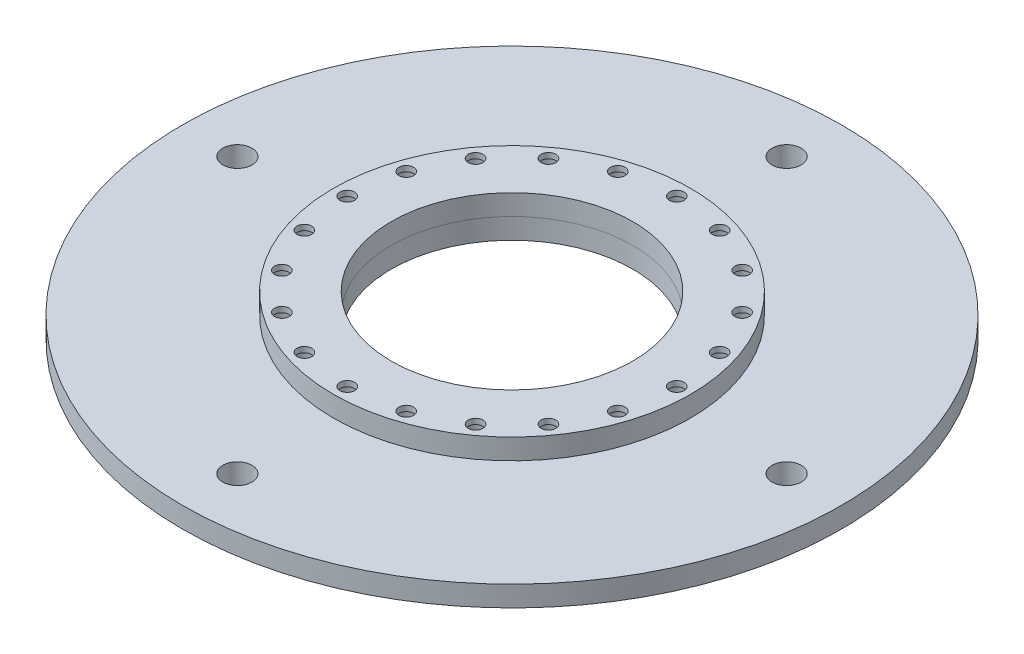
from build123d import *

# Parameters (mm, degrees)
SKETCH9_R                           = 82.55
SKETCH9_R_2                         = 55.88
REF_BACKPLATE_DEPTH                 = 9.525
REF_CBORE_BACKPLATE_D               = 6.7564
REF_CBORE_BACKPLATE_CBORE_D         = 11.176
REF_CBORE_BACKPLATE_CBORE_DEPTH     = 6.985
REF_CBORE_BACKPLATE_PATTERN_COUNT   = 20
SKETCH1_R                           = 152.4
SKETCH1_R_2                         = 55.88
THRUSTPLATE_TC3_DEPTH               = 9.525
SKETCH12_W                          = 6.74624
SKETCH12_H                          = 9.525
CLEARANCE_THRUSTPLATE_PATTERN_COUNT = 4
SKETCH23_W                          = 2.5527
SKETCH23_H                          = 9.525
CIRPATTERN1_COUNT                   = 10


with BuildPart() as part:
    # Sketch9 → REF_BackPlate (new body)
    with BuildSketch(Plane(origin=(0, 0, 0), x_dir=(1, 0, 0), z_dir=(0, 1, 0))):
        Circle(SKETCH9_R)
        Circle(SKETCH9_R_2, mode=Mode.SUBTRACT)
    extrude(amount=REF_BACKPLATE_DEPTH)

    # REF_CBORE_BackPlate (through all)
    with Locations(Plane(origin=(0, 0, 0), x_dir=(-1, 0, 0), z_dir=(0, -1, 0))):
        with Locations((0, 76.2)):
            ref_cbore_backplate = CounterBoreHole(REF_CBORE_BACKPLATE_D / 2, REF_CBORE_BACKPLATE_CBORE_D / 2, REF_CBORE_BACKPLATE_CBORE_DEPTH)

    # REF_CBORE_BackPlate_Pattern: REF_CBORE_BackPlate ×20 about axis
    ref_cbore_backplate_pattern_axis = Axis((0, 9.525, 0), (0, -1, 0))
    for i in range(1, REF_CBORE_BACKPLATE_PATTERN_COUNT):
        add(ref_cbore_backplate.rotate(ref_cbore_backplate_pattern_axis, i * 360 / REF_CBORE_BACKPLATE_PATTERN_COUNT), mode=Mode.SUBTRACT)


with BuildPart() as body_2:
    # Sketch1 → ThrustPlate_TC3 (new body)
    with BuildSketch(Plane(origin=(0, 0, 0), x_dir=(1, 0, 0), z_dir=(0, 1, 0))):
        Circle(SKETCH1_R)
        Circle(SKETCH1_R_2, mode=Mode.SUBTRACT)
    extrude(amount=-THRUSTPLATE_TC3_DEPTH)

    # Sketch12 → UNDEF_Clearance_ThrustPlate (revolve, cut)
    with BuildSketch(Plane(origin=(0, 0, -127), x_dir=(0, 0, 1), z_dir=(1, 0, 0))):
        with Locations((3.37312, 4.7625)):
            Rectangle(SKETCH12_W, SKETCH12_H)
    undef_clearance_thrustplate = revolve(axis=Axis((0, 6.35, -127), (0, -1, 0)), mode=Mode.SUBTRACT)

    # Clearance_ThrustPlate_Pattern: UNDEF_Clearance_ThrustPlate ×4 about axis
    clearance_thrustplate_pattern_axis = Axis((0, -9.525, 0), (0, 1, 0))
    for i in range(1, CLEARANCE_THRUSTPLATE_PATTERN_COUNT):
        add(undef_clearance_thrustplate.rotate(clearance_thrustplate_pattern_axis, i * 360 / CLEARANCE_THRUSTPLATE_PATTERN_COUNT), mode=Mode.SUBTRACT)

    # Sketch23 → 10 Clearance Hole1 (revolve, cut)
    with BuildSketch(Plane(origin=(0, 0, -70.32625), x_dir=(0, 0, 1), z_dir=(1, 0, 0))):
        with Locations((1.27635, 4.7625)):
            Rectangle(SKETCH23_W, SKETCH23_H)
    f_10_clearance_hole1 = revolve(axis=Axis((0, 6.35, -70.32625), (0, -1, 0)), mode=Mode.SUBTRACT)

    # CirPattern1: 10 Clearance Hole1 ×10 about axis
    cirpattern1_axis = Axis((0, -9.525, 0), (0, 1, 0))
    for i in range(1, CIRPATTERN1_COUNT):
        add(f_10_clearance_hole1.rotate(cirpattern1_axis, i * 360 / CIRPATTERN1_COUNT), mode=Mode.SUBTRACT)


solid = Compound([part.part, body_2.part])
